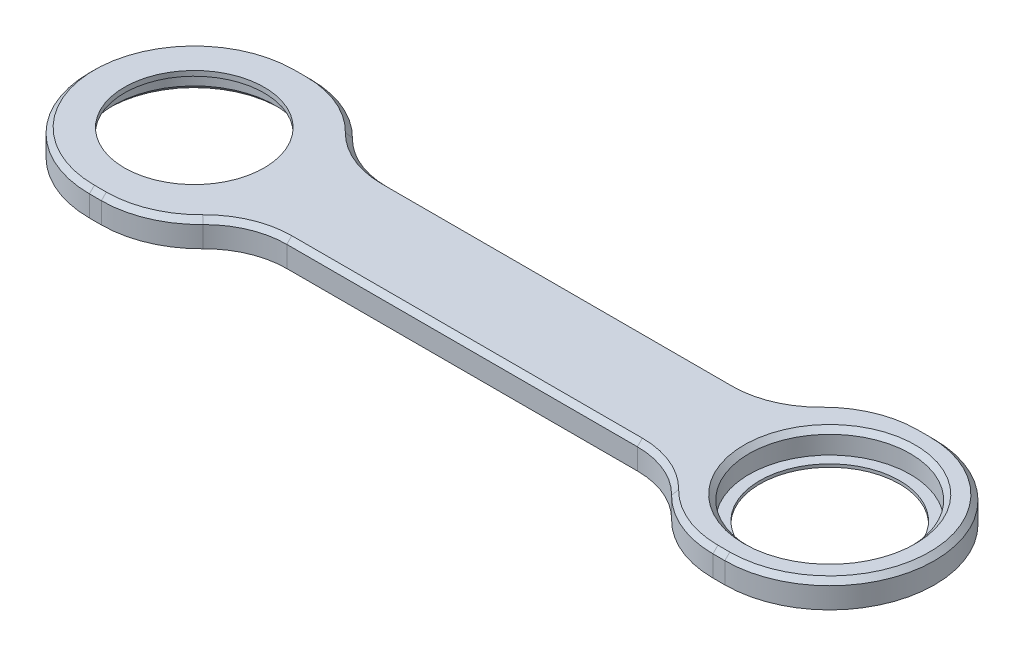
from build123d import *

# Parameters (mm, degrees)
SKETCH1_R           = 16.15
BOSS_EXTRUDE1_DEPTH = 5.2
FILLET1_R           = 20
CHAMFER1_SIZE       = 1
SKETCH2_R           = 19.025242353
SKETCH2_R_2         = 14
BOSS_EXTRUDE2_DEPTH = 0.6
SKETCH4_R           = 18.71529055
SKETCH4_R_2         = 14
BOSS_EXTRUDE3_DEPTH = 1
CHAMFER2_SIZE       = 1


with BuildPart() as part:
    # Sketch1 → Boss-Extrude1 (new body)
    with BuildSketch(Plane(origin=(0, 0, 0), x_dir=(1, 0, 0), z_dir=(0, 1, 0))):
        with BuildLine():
            Line((50.6952797, -21), (63.625, -21))
            ThreePointArc((63.625, -21), (84.625, 0), (63.625, 21))
            Line((63.625, 21), (50.6952797, 21))
            ThreePointArc((50.6952797, 21), (44.646090821, 13.026866227), (35.106613419, 10))
            Line((35.106613419, 10), (-35.106613419, 10))
            ThreePointArc((-35.106613419, 10), (-44.646090821, 13.026866227), (-50.6952797, 21))
            Line((-50.6952797, 21), (-63.625, 21))
            ThreePointArc((-63.625, 21), (-84.625, 0), (-63.625, -21))
            Line((-63.625, -21), (-50.6952797, -21))
            ThreePointArc((-50.6952797, -21), (-44.646090821, -13.026866227), (-35.106613419, -10))
            Line((-35.106613419, -10), (35.106613419, -10))
            ThreePointArc((35.106613419, -10), (44.646090821, -13.026866227), (50.6952797, -21))
        make_face()
        with Locations((-63.625, 0)):
            Circle(SKETCH1_R, mode=Mode.SUBTRACT)
        with Locations((63.625, 0)):
            Circle(SKETCH1_R, mode=Mode.SUBTRACT)
    extrude(amount=BOSS_EXTRUDE1_DEPTH)

    # Fillet1
    fillet1_edges = [part.edges().sort_by_distance(p)[0] for p in [
        (-50.6952797, 2.6, 21),
        (-50.6952797, 2.6, -21),
        (50.6952797, 2.6, -21),
        (50.6952797, 2.6, 21),
    ]]
    fillet(fillet1_edges, radius=FILLET1_R)

    # Chamfer1
    chamfer1_edges = [part.edges().sort_by_distance(p)[0] for p in [
        (62.433003391, 5.2, 21),
        (84.625, 5.2, 0),
        (62.433003391, 5.2, -21),
        (41.52534742, 5.2, -11.295776268),
        (0, 5.2, -10),
        (41.52534742, 5.2, 11.295776268),
        (-41.52534742, 5.2, -11.295776268),
        (-62.433003391, 5.2, -21),
        (-62.433003391, 5.2, 21),
        (-53.482236449, 5.2, 19.433705079),
        (-53.482236449, 5.2, -19.433705079),
        (-84.625, 5.2, 0),
        (53.482236449, 5.2, -19.433705079),
        (53.482236449, 5.2, 19.433705079),
        (-41.52534742, 5.2, 11.295776268),
        (0, 5.2, 10),
        (47.475, 5.2, 0),
    ]]
    chamfer(chamfer1_edges, length=CHAMFER1_SIZE)

    # Sketch2 → Boss-Extrude2 (add)
    with BuildSketch(Plane.XZ):
        with Locations((63.625, 0)):
            Circle(SKETCH2_R)
        with Locations((63.625, 0)):
            Circle(SKETCH2_R_2, mode=Mode.SUBTRACT)
    extrude(amount=-BOSS_EXTRUDE2_DEPTH)

    # Sketch4 → Boss-Extrude3 (add)
    with BuildSketch(Plane(origin=(0, 5.2, 0), x_dir=(1, 0, 0), z_dir=(0, 1, 0))):
        with Locations((-63.625, 0)):
            Circle(SKETCH4_R)
        with Locations((-63.625, 0)):
            Circle(SKETCH4_R_2, mode=Mode.SUBTRACT)
    extrude(amount=-BOSS_EXTRUDE3_DEPTH)

    # Chamfer2
    chamfer2_edges = [part.edges().sort_by_distance(p)[0] for p in [
        (-79.775, 0, 0),
    ]]
    chamfer(chamfer2_edges, length=CHAMFER2_SIZE)


solid = part.part
